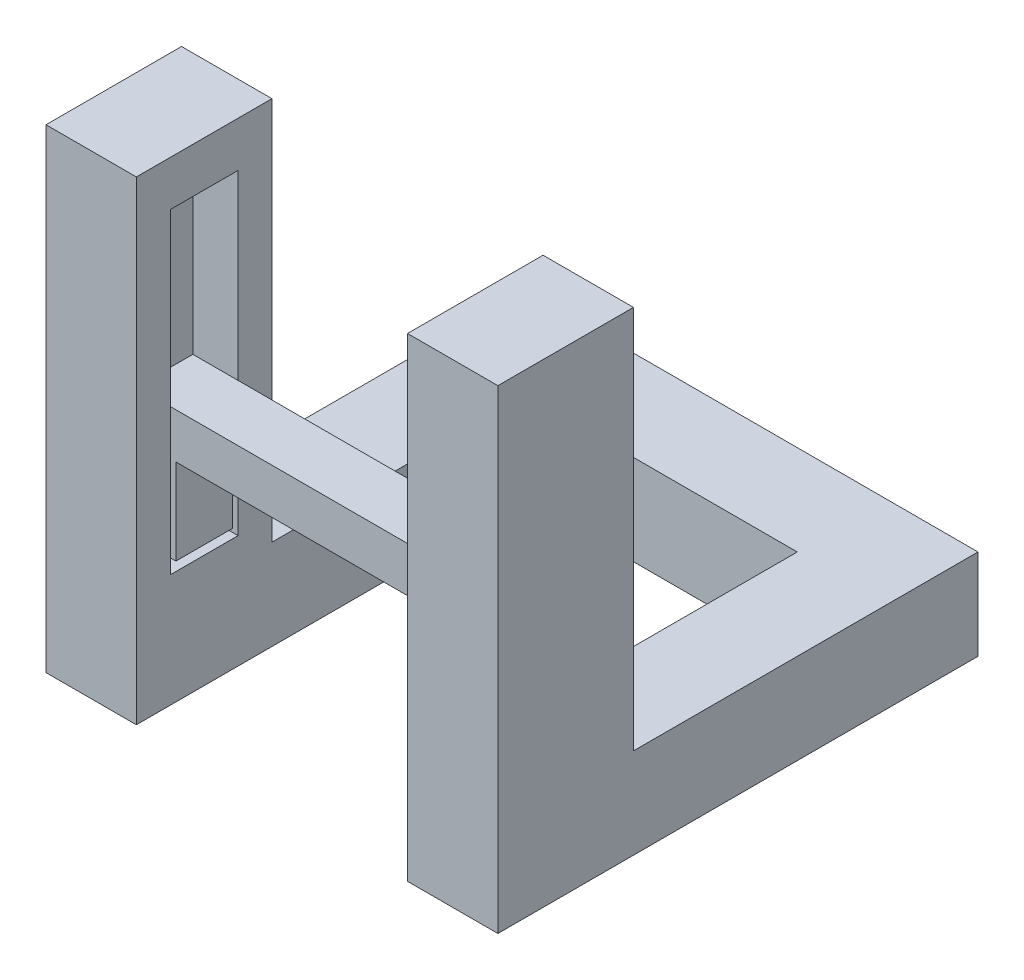
from build123d import *

# Parameters (mm, degrees)
SKETCH1_W             = 4
SKETCH1_H             = 6
BOSS_EXTRUDE1_DEPTH   = 13
BOSS_EXTRUDE1_2_DEPTH = 13
SKETCH2_W             = 2
SKETCH2_H             = 3
CUT_EXTRUDE1_DEPTH    = 4
SKETCH4_W             = 1.75
SKETCH4_H             = 2.5
BOSS_EXTRUDE2_DEPTH   = 4.2
BOSS_EXTRUDE2_2_DEPTH = 4.2
SKETCH5_W             = 15.5
SKETCH5_H             = 2.5
BOSS_EXTRUDE3_DEPTH   = 2
BOSS_EXTRUDE4_DEPTH   = 10
SKETCH8_W             = 4
SKETCH8_H             = 6
CUT_EXTRUDE2_DEPTH    = 4
CUT_EXTRUDE3_REACH    = 30.653
SKETCH9_W             = 2.5
SKETCH9_H             = 0.4
SKETCH10_W            = 2.5
SKETCH10_H            = 0.4
CUT_EXTRUDE4_DEPTH    = 2
BOSS_EXTRUDE5_DEPTH   = 4
SKETCH14_W            = 4
SKETCH14_H            = 6
BOSS_EXTRUDE7_DEPTH   = 2


with BuildPart() as part:
    # Sketch1 → Boss-Extrude1 (new body)
    with BuildSketch(Plane(origin=(0, 0, 0), x_dir=(1, 0, 0), z_dir=(0, 1, 0))):
        with Locations((18, 3)):
            Rectangle(SKETCH1_W, SKETCH1_H)
    extrude(amount=BOSS_EXTRUDE1_DEPTH)


with BuildPart() as body_2:
    # Sketch1 → Boss-Extrude1 2 (new body)
    with BuildSketch(Plane(origin=(0, 0, 0), x_dir=(1, 0, 0), z_dir=(0, 1, 0))):
        with Locations((2, 3)):
            Rectangle(SKETCH1_W, SKETCH1_H)
    extrude(amount=BOSS_EXTRUDE1_2_DEPTH)


with BuildPart() as cut_extrude1_tool:
    # Sketch2 → Cut-Extrude1 (new body)
    with BuildSketch(Plane(origin=(0, 13, 0), x_dir=(1, 0, 0), z_dir=(0, 1, 0))):
        with Locations((17, 3)):
            Rectangle(SKETCH2_W, SKETCH2_H)
        with Locations((3, 3)):
            Rectangle(SKETCH2_W, SKETCH2_H)
    extrude(amount=-CUT_EXTRUDE1_DEPTH)


with BuildPart() as part_1:
    add(part.part)

    # Cut-Extrude1: cut by cut_extrude1_tool
    add(cut_extrude1_tool.part, mode=Mode.SUBTRACT)



with BuildPart() as body_2_1:
    add(body_2.part)

    # Cut-Extrude1: cut by cut_extrude1_tool
    add(cut_extrude1_tool.part, mode=Mode.SUBTRACT)


with BuildPart() as body_3:
    # Sketch4 → Boss-Extrude2 (new body)
    with BuildSketch(Plane(origin=(0, 9, 0), x_dir=(1, 0, 0), z_dir=(0, 1, 0))):
        with Locations((16.875, 3)):
            Rectangle(SKETCH4_W, SKETCH4_H)
    extrude(amount=BOSS_EXTRUDE2_DEPTH)



with BuildPart() as body_4:
    # Sketch4 → Boss-Extrude2 2 (new body)
    with BuildSketch(Plane(origin=(0, 9, 0), x_dir=(1, 0, 0), z_dir=(0, 1, 0))):
        with Locations((3.125, 3)):
            Rectangle(SKETCH4_W, SKETCH4_H)
    extrude(amount=BOSS_EXTRUDE2_2_DEPTH)


with BuildPart() as body_3_1:
    add(body_3.part)

    add(body_4.part)  # Boss-Extrude3 merges body 4
    # Sketch5 → Boss-Extrude3 (add)
    with BuildSketch(Plane(origin=(0, 13.2, 0), x_dir=(1, 0, 0), z_dir=(0, 1, 0))):
        with Locations((10, 3)):
            Rectangle(SKETCH5_W, SKETCH5_H)
    extrude(amount=BOSS_EXTRUDE3_DEPTH)


with BuildPart() as part_2:
    add(part_1.part)

    add(body_3_1.part)  # Boss-Extrude4 merges body 3

    add(body_2_1.part)  # Boss-Extrude4 merges body 2
    # Sketch7 → Boss-Extrude4 (add)
    with BuildSketch(Plane(origin=(0, 13, 0), x_dir=(1, 0, 0), z_dir=(0, 1, 0))):
        Polygon((16, 4.5), (16, 6), (20, 6), (20, 0), (16, 0), (16, 1.5), (18, 1.5), (18, 4.5), align=None)
        Polygon((4, 6), (0, 6), (0, 0), (4, 0), (4, 1.5), (2, 1.5), (2, 4.5), (4, 4.5), align=None)
    extrude(amount=BOSS_EXTRUDE4_DEPTH)

    # Sketch8 → Cut-Extrude2 (cut)
    with BuildSketch(Plane.XZ):
        with Locations((2, -3)):
            Rectangle(SKETCH8_W, SKETCH8_H)
        with Locations((18, -3)):
            Rectangle(SKETCH8_W, SKETCH8_H)
    extrude(amount=-CUT_EXTRUDE2_DEPTH, mode=Mode.SUBTRACT)

    # Sketch9 → Cut-Extrude3 (cut, up to next)
    with BuildSketch(Plane(origin=(4, 0, 0), x_dir=(0, 0, -1), z_dir=(1, 0, 0)), mode=Mode.PRIVATE) as cut_extrude3_sk1:
        with Locations((3, 9.2)):
            Rectangle(SKETCH9_W, SKETCH9_H)
    cut_extrude3_tool1 = extrude(cut_extrude3_sk1.sketch, amount=-CUT_EXTRUDE3_REACH, mode=Mode.PRIVATE) & part_2.part
    add(cut_extrude3_tool1.solids().sort_by_distance((4, 9.2, -3))[0], mode=Mode.SUBTRACT)


with BuildPart() as cut_extrude3_piece_1:
    # of the separate pieces the step leaves, piece 1, a body of its own (cut_extrude3_pieces)
    add(part_2.part.solids().sort_by_distance((4, 9.4, -4.25))[0])

    # Sketch10 → Cut-Extrude4 (cut)
    with BuildSketch(Plane.ZY.offset(-16)):
        with Locations((-3, 9.2)):
            Rectangle(SKETCH10_W, SKETCH10_H)
    extrude(amount=-CUT_EXTRUDE4_DEPTH, mode=Mode.SUBTRACT)


with BuildPart() as cut_extrude3_piece_2:
    # of the separate pieces the step leaves, piece 2, a body of its own (cut_extrude3_pieces)
    add(part_2.part.solids().sort_by_distance((0, 23, -6))[0])



with BuildPart() as cut_extrude4_piece_1:
    # of the separate pieces the step leaves, piece 1, a body of its own (cut_extrude4_pieces)
    add(cut_extrude3_piece_1.part.solids().sort_by_distance((16, 9, -4.5))[0])


with BuildPart() as cut_extrude4_piece_2:
    # of the separate pieces the step leaves, piece 2, a body of its own (cut_extrude4_pieces)
    add(cut_extrude3_piece_1.part.solids().sort_by_distance((4, 9.4, -4.25))[0])


with BuildPart() as cut_extrude3_piece_2_1:
    add(cut_extrude3_piece_2.part)

    add(cut_extrude4_piece_1.part)  # Boss-Extrude5 merges Cut-Extrude4 piece 1
    # Sketch12 → Boss-Extrude5 (add)
    with BuildSketch(Plane.XZ.offset(-4)):
        Polygon((20, -21.25), (20, -6), (16, -6), (16, -17.25), (4, -17.25), (4, -6), (0, -6), (0, -21.25), align=None)
    extrude(amount=-BOSS_EXTRUDE5_DEPTH)

    # Sketch14 → Boss-Extrude7 (add)
    with BuildSketch(Plane(origin=(0, 23, 0), x_dir=(1, 0, 0), z_dir=(0, 1, 0))):
        with Locations((18, 3)):
            Rectangle(SKETCH14_W, SKETCH14_H)
        with Locations((2, 3)):
            Rectangle(SKETCH14_W, SKETCH14_H)
    extrude(amount=BOSS_EXTRUDE7_DEPTH)


solid = Compound([cut_extrude4_piece_2.part, cut_extrude3_piece_2_1.part])
